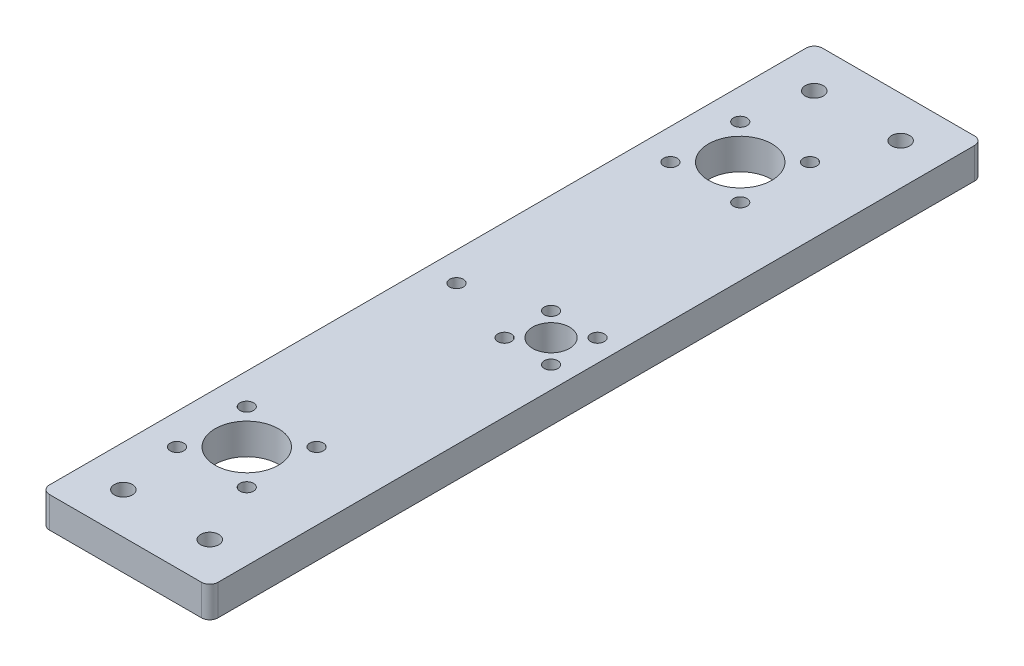
from build123d import *

# Parameters (mm, degrees)
SKETCH1_R           = 2.2
SKETCH1_R_2         = 1.65
SKETCH1_R_3         = 7.7
SKETCH1_R_4         = 4.5
BOSS_EXTRUDE1_DEPTH = 7.5


with BuildPart() as part:
    # Sketch1 → Boss-Extrude1 (new body)
    with BuildSketch(Plane(origin=(0, 7.5, 0), x_dir=(1, 0, 0), z_dir=(0, 1, 0))):
        with BuildLine():
            Line((18.5, 94), (-18.5, 94))
            ThreePointArc((-18.5, 94), (-19.914213562, 93.414213562), (-20.5, 92))
            Line((-20.5, 92), (-20.5, -92))
            ThreePointArc((-20.5, -92), (-19.914213562, -93.414213562), (-18.5, -94))
            Line((-18.5, -94), (18.5, -94))
            ThreePointArc((18.5, -94), (19.914213562, -93.414213562), (20.5, -92))
            Line((20.5, -92), (20.5, 92))
            ThreePointArc((20.5, 92), (19.914213562, 93.414213562), (18.5, 94))
        make_face()
        with Locations((10.5, 84)):
            Circle(SKETCH1_R, mode=Mode.SUBTRACT)
        with Locations((-10.5, 84)):
            Circle(SKETCH1_R, mode=Mode.SUBTRACT)
        with Locations((10.5, -84)):
            Circle(SKETCH1_R, mode=Mode.SUBTRACT)
        with Locations((-10.5, -84)):
            Circle(SKETCH1_R, mode=Mode.SUBTRACT)
        with Locations((3.985281374, 51.514718626)):
            Circle(SKETCH1_R_2, mode=Mode.SUBTRACT)
        with Locations((15.156854249, 5.656854249)):
            Circle(SKETCH1_R_2, mode=Mode.SUBTRACT)
        with Locations((-12.985281374, -68.485281374)):
            Circle(SKETCH1_R_2, mode=Mode.SUBTRACT)
        with Locations((3.985281374, -68.485281374)):
            Circle(SKETCH1_R_2, mode=Mode.SUBTRACT)
        with Locations((-4.5, -60)):
            Circle(SKETCH1_R_3, mode=Mode.SUBTRACT)
        with Locations((9.5, 0)):
            Circle(SKETCH1_R_4, mode=Mode.SUBTRACT)
        with Locations((-12.985281374, -51.514718626)):
            Circle(SKETCH1_R_2, mode=Mode.SUBTRACT)
        with Locations((3.985281374, -51.514718626)):
            Circle(SKETCH1_R_2, mode=Mode.SUBTRACT)
        with Locations((3.985281374, 68.485281374)):
            Circle(SKETCH1_R_2, mode=Mode.SUBTRACT)
        with Locations((-12.985281374, 68.485281374)):
            Circle(SKETCH1_R_2, mode=Mode.SUBTRACT)
        with Locations((-12.985281374, 51.514718626)):
            Circle(SKETCH1_R_2, mode=Mode.SUBTRACT)
        with Locations((3.843145751, 5.656854249)):
            Circle(SKETCH1_R_2, mode=Mode.SUBTRACT)
        with Locations((3.843145751, -5.656854249)):
            Circle(SKETCH1_R_2, mode=Mode.SUBTRACT)
        with Locations((15.156854249, -5.656854249)):
            Circle(SKETCH1_R_2, mode=Mode.SUBTRACT)
        with Locations((-13.5, 0)):
            Circle(SKETCH1_R_2, mode=Mode.SUBTRACT)
        with Locations((-4.5, 60)):
            Circle(SKETCH1_R_3, mode=Mode.SUBTRACT)
    extrude(amount=-BOSS_EXTRUDE1_DEPTH)


solid = part.part
